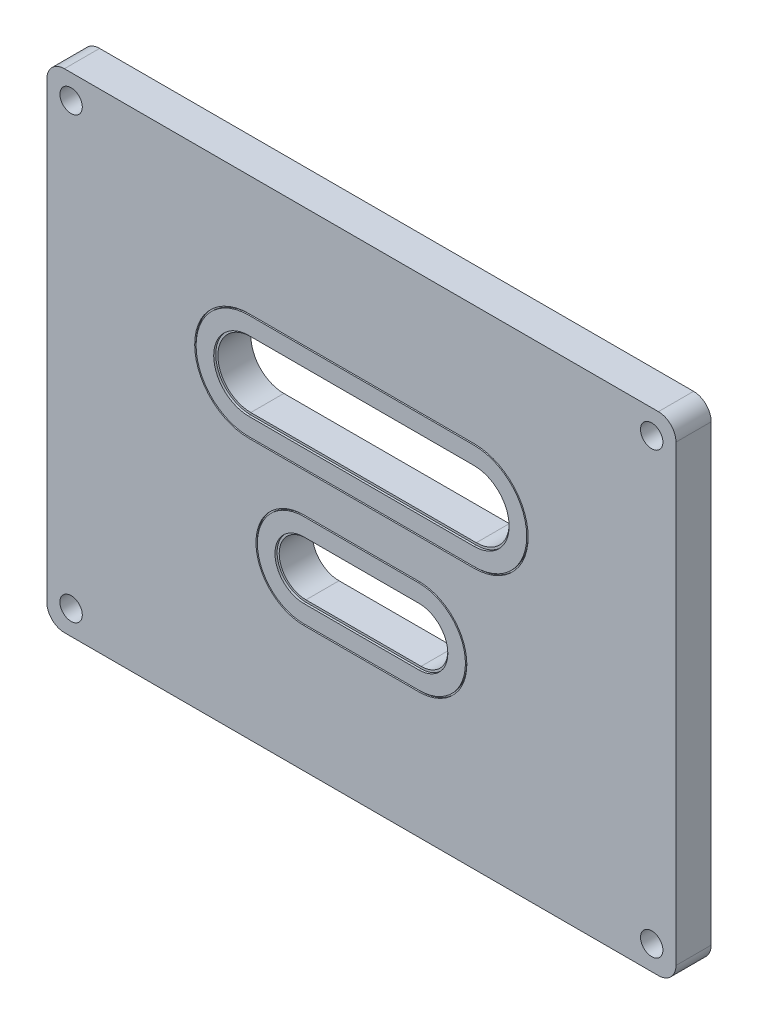
from build123d import *

# Parameters (mm, degrees)
SKETCH1_W                 = 113.538
SKETCH1_H                 = 88.138
EXTRUDE1_DEPTH            = 6.35
F_8_CLEARANCE_HOLE1_D     = 4.0386
F_8_CLEARANCE_HOLE1_DEPTH = 6.35
FILLET2_R                 = 3.175
SKETCH8_W                 = 40.6908
SKETCH8_H                 = 12.6238
SKETCH8_W_2               = 20.7772
SKETCH8_H_2               = 10.414
CUT_EXTRUDE1_DEPTH        = 0.381
CUT_EXTRUDE2_DEPTH        = 7.35
CUT_EXTRUDE3_DEPTH        = 0.254


with BuildPart() as part:
    # Sketch1 → Extrude1 (new body)
    with BuildSketch(Plane.XY):
        Rectangle(SKETCH1_W, SKETCH1_H)
    extrude(amount=EXTRUDE1_DEPTH)

    # #8 Clearance Hole1
    with Locations(Plane(origin=(-52.3875, 39.6875, 6.35), x_dir=(1, 0, 0), z_dir=(0, 0, 1))):
        with Locations((0, 0), (104.775, 0), (104.775, -79.375), (0, -79.375)):
            Hole(F_8_CLEARANCE_HOLE1_D / 2, depth=F_8_CLEARANCE_HOLE1_DEPTH)

    # Fillet2
    fillet2_edges = [part.edges().sort_by_distance(p)[0] for p in [
        (-56.769, 44.069, 3.175),
        (56.769, 44.069, 3.175),
        (56.769, -44.069, 3.175),
        (-56.769, -44.069, 3.175),
    ]]
    fillet(fillet2_edges, radius=FILLET2_R)

    # Sketch8 → Cut-Extrude1 (cut)
    with BuildSketch(Plane.XY.offset(6.35)):
        with BuildLine():
            ThreePointArc((-20.3454, 6.3881), (-26.6573, 12.7), (-20.3454, 19.0119))
            Line((-20.3454, 19.0119), (-20.3454, 6.3881))
        make_face()
        with Locations((0, 12.7)):
            Rectangle(SKETCH8_W, SKETCH8_H)
        with BuildLine():
            ThreePointArc((20.3454, 19.0119), (26.6573, 12.7), (20.3454, 6.3881))
            Line((20.3454, 6.3881), (20.3454, 19.0119))
        make_face()
        with BuildLine():
            ThreePointArc((10.3886, -7.493), (15.5956, -12.7), (10.3886, -17.907))
            Line((10.3886, -17.907), (10.3886, -7.493))
        make_face()
        with Locations((0, -12.7)):
            Rectangle(SKETCH8_W_2, SKETCH8_H_2)
        with BuildLine():
            Line((-10.3886, -17.907), (-10.3886, -7.493))
            ThreePointArc((-10.3886, -7.493), (-15.5956, -12.7), (-10.3886, -17.907))
        make_face()
    extrude(amount=-CUT_EXTRUDE1_DEPTH, mode=Mode.SUBTRACT)

    # Sketch9 → Cut-Extrude2 (cut, through all)
    with BuildSketch(Plane.XY.offset(6.35)):
        with BuildLine():
            Line((-20.3454, 6.7691), (20.3454, 6.7691))
            ThreePointArc((20.3454, 6.7691), (26.2763, 12.7), (20.3454, 18.6309))
            Line((20.3454, 18.6309), (-20.3454, 18.6309))
            ThreePointArc((-20.3454, 18.6309), (-26.2763, 12.7), (-20.3454, 6.7691))
        make_face()
        with BuildLine():
            Line((10.3886, -7.874), (-10.3886, -7.874))
            ThreePointArc((-10.3886, -7.874), (-15.2146, -12.7), (-10.3886, -17.526))
            Line((-10.3886, -17.526), (10.3886, -17.526))
            ThreePointArc((10.3886, -17.526), (15.2146, -12.7), (10.3886, -7.874))
        make_face()
    extrude(amount=-CUT_EXTRUDE2_DEPTH, mode=Mode.SUBTRACT)

    # Sketch10 → Cut-Extrude3 (cut)
    with BuildSketch(Plane.XY.offset(6.35)):
        with BuildLine():
            Line((20.3454, 2.9591), (-20.3454, 2.9591))
            ThreePointArc((-20.3454, 2.9591), (-30.0863, 12.7), (-20.3454, 22.4409))
            Line((-20.3454, 22.4409), (20.3454, 22.4409))
            ThreePointArc((20.3454, 22.4409), (30.0863, 12.7), (20.3454, 2.9591))
        make_face()
        with BuildLine():
            ThreePointArc((20.3454, 3.2131), (29.8323, 12.7), (20.3454, 22.1869))
            Line((20.3454, 22.1869), (-20.3454, 22.1869))
            ThreePointArc((-20.3454, 22.1869), (-29.8323, 12.7), (-20.3454, 3.2131))
            Line((-20.3454, 3.2131), (20.3454, 3.2131))
        make_face(mode=Mode.SUBTRACT)
        with BuildLine():
            Line((10.3886, -21.336), (-10.3886, -21.336))
            ThreePointArc((-10.3886, -21.336), (-19.0246, -12.7), (-10.3886, -4.064))
            Line((-10.3886, -4.064), (10.3886, -4.064))
            ThreePointArc((10.3886, -4.064), (19.0246, -12.7), (10.3886, -21.336))
        make_face()
        with BuildLine():
            ThreePointArc((10.3886, -21.082), (18.7706, -12.7), (10.3886, -4.318))
            Line((10.3886, -4.318), (-10.3886, -4.318))
            ThreePointArc((-10.3886, -4.318), (-18.7706, -12.7), (-10.3886, -21.082))
            Line((-10.3886, -21.082), (10.3886, -21.082))
        make_face(mode=Mode.SUBTRACT)
    extrude(amount=-CUT_EXTRUDE3_DEPTH, mode=Mode.SUBTRACT)


solid = part.part
